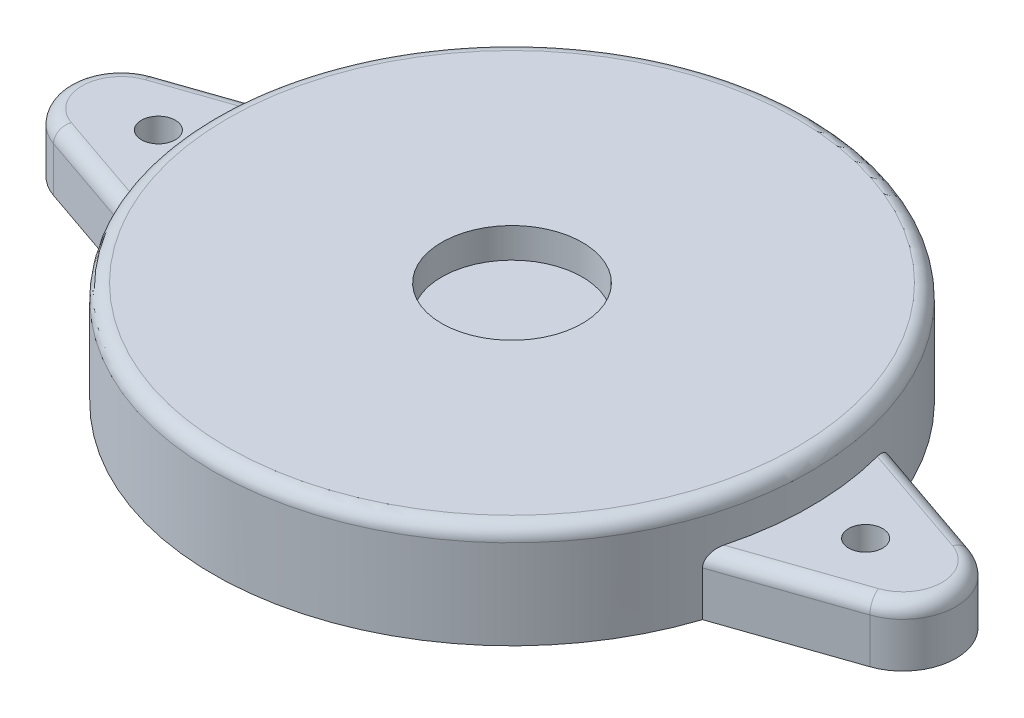
from build123d import *

# Parameters (mm, degrees)
SKETCH1_R           = 14.93
BOSS_EXTRUDE1_DEPTH = 5.16
SKETCH2_R           = 0.85
BOSS_EXTRUDE2_DEPTH = 2.94
FILLET2_R           = 0.7
FILLET4_R           = 0.7
SKETCH3_R           = 3.515
CUT_EXTRUDE1_DEPTH  = 1.5


with BuildPart() as part:
    # Sketch1 → Boss-Extrude1 (new body)
    with BuildSketch(Plane(origin=(0, 0, 0), x_dir=(1, 0, 0), z_dir=(0, 1, 0))):
        Circle(SKETCH1_R)
    extrude(amount=BOSS_EXTRUDE1_DEPTH)

    # Sketch2 → Boss-Extrude2 (add)
    with BuildSketch(Plane(origin=(0, 0, 0), x_dir=(1, 0, 0), z_dir=(0, 1, 0))):
        with BuildLine():
            Line((-14.184219953, -4.659700025), (-20.406728453, -2.514915627))
            ThreePointArc((-20.406728453, -2.514915627), (-22.2, 0), (-20.406728453, 2.514915627))
            Line((-20.406728453, 2.514915627), (-14.184219953, 4.659700025))
            ThreePointArc((-14.184219953, 4.659700025), (-14.93, 0), (-14.184219953, -4.659700025))
        make_face()
        with Locations((-17.68, 0)):
            Circle(SKETCH2_R, mode=Mode.SUBTRACT)
        with BuildLine():
            Line((14.184219953, 4.659700025), (20.406728453, 2.514915627))
            ThreePointArc((20.406728453, 2.514915627), (22.2, 0), (20.406728453, -2.514915627))
            Line((20.406728453, -2.514915627), (14.184219953, -4.659700025))
            ThreePointArc((14.184219953, -4.659700025), (14.93, 0), (14.184219953, 4.659700025))
        make_face()
        with Locations((17.68, 0)):
            Circle(SKETCH2_R, mode=Mode.SUBTRACT)
    extrude(amount=BOSS_EXTRUDE2_DEPTH)

    # Fillet2
    fillet2_edges = [part.edges().sort_by_distance(p)[0] for p in [
        (-14.93, 5.16, 0),
    ]]
    fillet(fillet2_edges, radius=FILLET2_R)

    # Fillet4
    fillet4_edges = [part.edges().sort_by_distance(p)[0] for p in [
        (-22.2, 2.94, 0),
        (-17.295474203, 2.94, 3.587307826),
        (-17.295474203, 2.94, -3.587307826),
        (17.295474203, 2.94, 3.587307826),
        (22.2, 2.94, 0),
        (17.295474203, 2.94, -3.587307826),
    ]]
    fillet(fillet4_edges, radius=FILLET4_R)

    # Sketch3 → Cut-Extrude1 (cut)
    with BuildSketch(Plane(origin=(0, 5.16, 0), x_dir=(1, 0, 0), z_dir=(0, 1, 0))):
        Circle(SKETCH3_R)
    extrude(amount=-CUT_EXTRUDE1_DEPTH, mode=Mode.SUBTRACT)


solid = part.part
